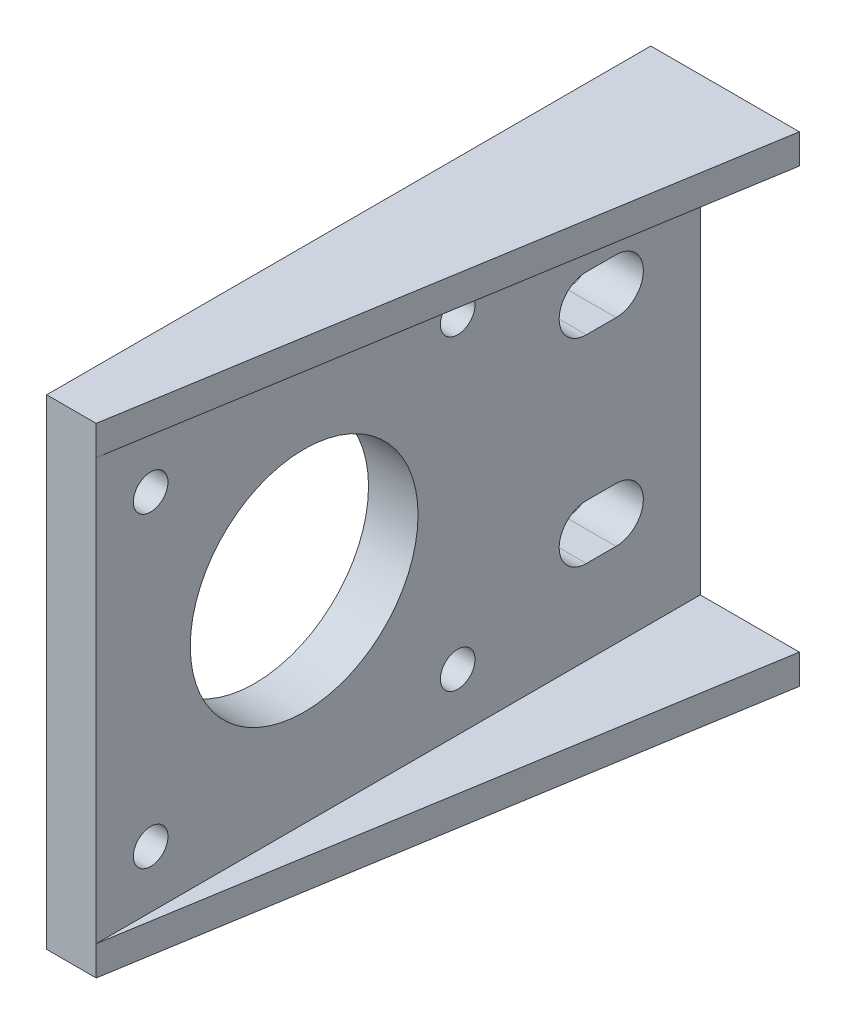
from build123d import *

# Parameters (mm, degrees)
SKETCH2_W           = 61
SKETCH2_H           = 42.5
SKETCH2_R           = 11.5
SKETCH2_R_2         = 1.75
BOSS_EXTRUDE2_DEPTH = 5
BOSS_EXTRUDE3_DEPTH = 3
LPATTERN1_COUNT     = 2
LPATTERN1_PITCH     = 45.5


with BuildPart() as part:
    # Sketch2 → Boss-Extrude2 (new body)
    with BuildSketch(Plane(origin=(0, 0, 0), x_dir=(0, 0, -1), z_dir=(1, 0, 0))):
        with Locations((9.5, 0)):
            Rectangle(SKETCH2_W, SKETCH2_H)
        Circle(SKETCH2_R, mode=Mode.SUBTRACT)
        with Locations((-15.5, 15.5)):
            Circle(SKETCH2_R_2, mode=Mode.SUBTRACT)
        with Locations((15.5, -15.5)):
            Circle(SKETCH2_R_2, mode=Mode.SUBTRACT)
        with Locations((15.5, 15.5)):
            Circle(SKETCH2_R_2, mode=Mode.SUBTRACT)
        with Locations((-15.5, -15.5)):
            Circle(SKETCH2_R_2, mode=Mode.SUBTRACT)
        with BuildLine():
            Line((28.5, 12.75), (31.5, 12.75))
            ThreePointArc((31.5, 12.75), (34.25, 10), (31.5, 7.25))
            Line((31.5, 7.25), (28.5, 7.25))
            ThreePointArc((28.5, 7.25), (25.75, 10), (28.5, 12.75))
        make_face(mode=Mode.SUBTRACT)
        with BuildLine():
            Line((28.5, -12.75), (31.5, -12.75))
            ThreePointArc((31.5, -12.75), (34.25, -10), (31.5, -7.25))
            Line((31.5, -7.25), (28.5, -7.25))
            ThreePointArc((28.5, -7.25), (25.75, -10), (28.5, -12.75))
        make_face(mode=Mode.SUBTRACT)
    extrude(amount=BOSS_EXTRUDE2_DEPTH)

    # Sketch4 → Boss-Extrude3 (add)
    with BuildSketch(Plane.XZ.offset(21.25)):
        Polygon((0, -40), (15, -40), (5, 21), (0, 21), align=None)
    boss_extrude3 = extrude(amount=BOSS_EXTRUDE3_DEPTH)

    # LPattern1: Boss-Extrude3 ×2
    with Locations(*[(0, i * LPATTERN1_PITCH, 0) for i in range(1, LPATTERN1_COUNT)]):
        add(boss_extrude3)


solid = part.part
